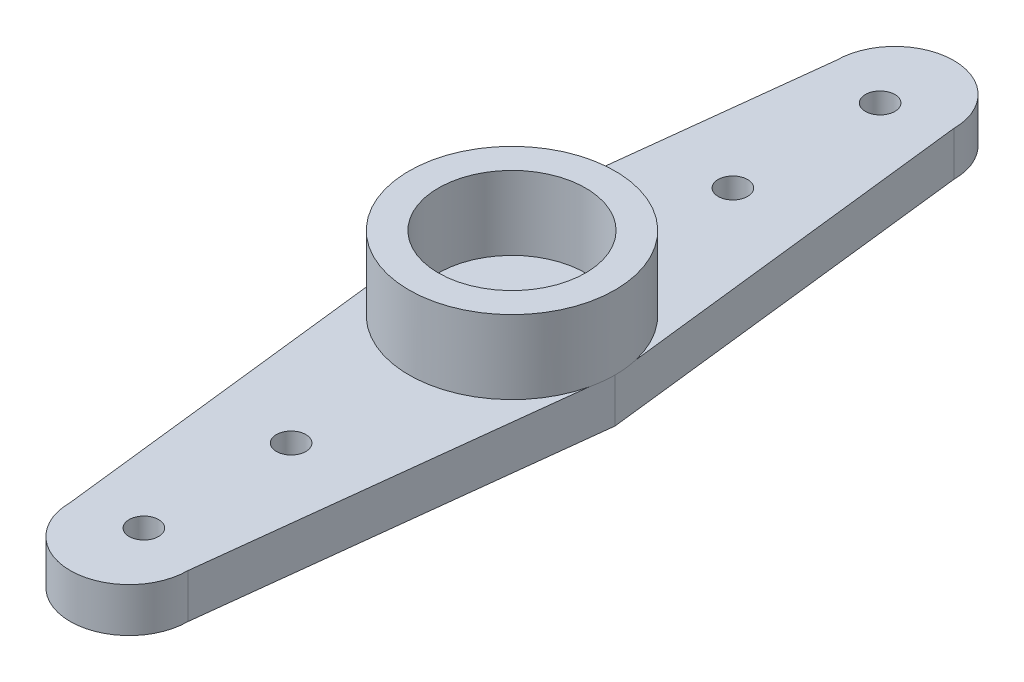
from build123d import *

# Parameters (mm, degrees)
EXTRUDE_2_DEPTH     = 1.5
SKETCH_7_R          = 3.5
EXTRUDE_3_DEPTH     = 2.5
SKETCH_8_R          = 2.5
CUT_EXTRUDE_1_DEPTH = 2.5
SKETCH_9_R          = 2.25
CUT_EXTRUDE_2_DEPTH = 0.5
SKETCH_10_R         = 0.9
CUT_EXTRUDE_3_DEPTH = 1
SKETCH_11_R         = 0.5
CUT_EXTRUDE_4_DEPTH = 1.5


with BuildPart() as part:
    # Эскиз1 → Бобышка-Вытянуть2 (new body)
    with BuildSketch(Plane(origin=(0, 0, 0), x_dir=(1, 0, 0), z_dir=(0, 1, 0))):
        with BuildLine():
            ThreePointArc((2, 13), (0, 15), (-2, 13))
            Line((-2, 13), (-3.5, 0))
            Line((-3.5, 0), (-2, -13))
            ThreePointArc((-2, -13), (0, -15), (2, -13))
            Line((2, -13), (3.5, 0))
            Line((3.5, 0), (2, 13))
        make_face()
    extrude(amount=EXTRUDE_2_DEPTH)

    # Эскиз7 → Бобышка-Вытянуть3 (add)
    with BuildSketch(Plane(origin=(0, 1.5, 0), x_dir=(1, 0, 0), z_dir=(0, 1, 0))):
        Circle(SKETCH_7_R)
    extrude(amount=EXTRUDE_3_DEPTH)

    # Эскиз8 → Вырез-Вытянуть1 (cut)
    with BuildSketch(Plane(origin=(0, 4, 0), x_dir=(1, 0, 0), z_dir=(0, 1, 0))):
        Circle(SKETCH_8_R)
    extrude(amount=-CUT_EXTRUDE_1_DEPTH, mode=Mode.SUBTRACT)

    # Эскиз9 → Вырез-Вытянуть2 (cut)
    with BuildSketch(Plane.XZ):
        Circle(SKETCH_9_R)
    extrude(amount=-CUT_EXTRUDE_2_DEPTH, mode=Mode.SUBTRACT)

    # Эскиз10 → Вырез-Вытянуть3 (cut)
    with BuildSketch(Plane.XZ.offset(-0.5)):
        Circle(SKETCH_10_R)
    extrude(amount=-CUT_EXTRUDE_3_DEPTH, mode=Mode.SUBTRACT)

    # Эскиз11 → Вырез-Вытянуть4 (cut)
    with BuildSketch(Plane.XZ):
        with Locations((0, -7.5)):
            Circle(SKETCH_11_R)
        with Locations((0, -12.5)):
            Circle(SKETCH_11_R)
        with Locations((0, 12.5)):
            Circle(SKETCH_11_R)
        with Locations((0, 7.5)):
            Circle(SKETCH_11_R)
    extrude(amount=-CUT_EXTRUDE_4_DEPTH, mode=Mode.SUBTRACT)


solid = part.part
